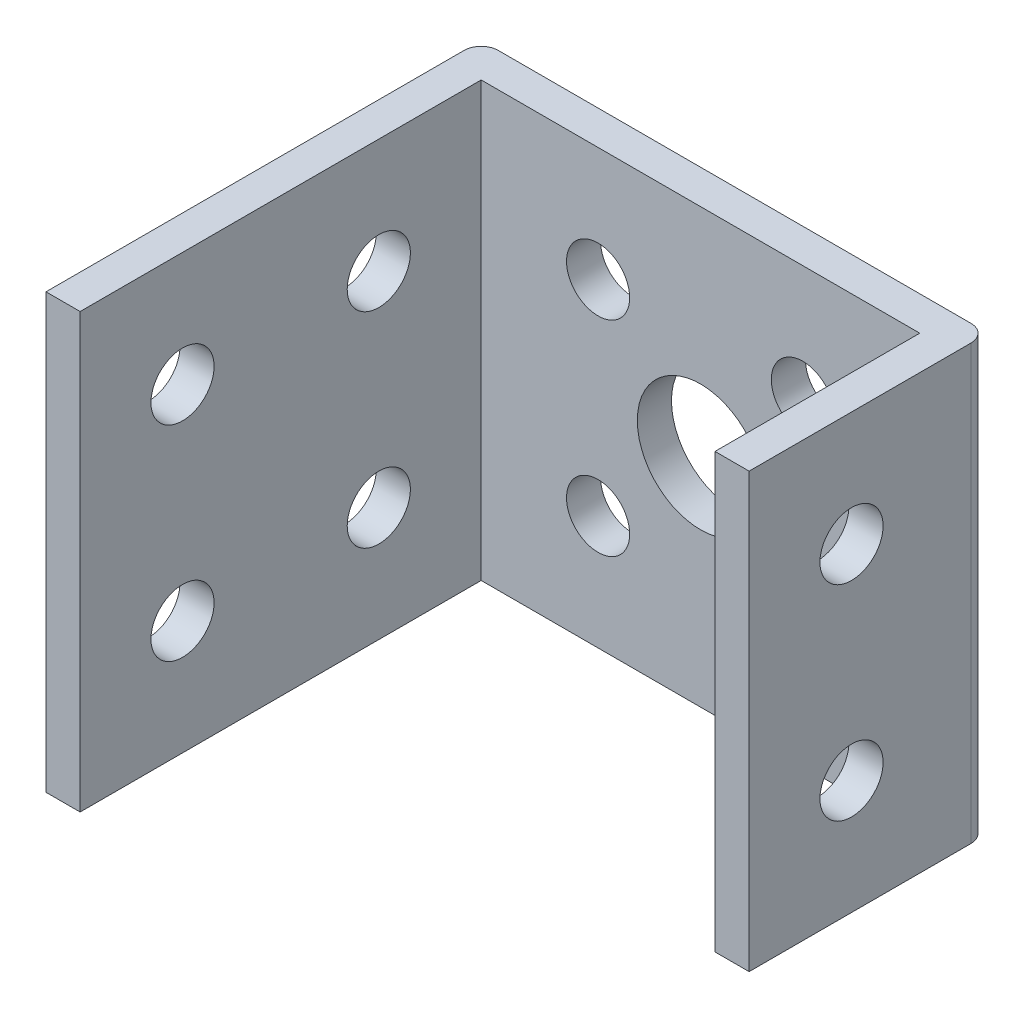
from build123d import *

# Parameters (mm, degrees)
BOSS_EXTRUDE1_DEPTH = 12.7
SKETCH2_R           = 1.85
CUT_EXTRUDE1_DEPTH  = 30.7
SKETCH3_R           = 3.7
CUT_EXTRUDE2_DEPTH  = 15
SKETCH4_R           = 1.85
CUT_EXTRUDE3_DEPTH  = 3
SKETCH5_W           = 11.5
SKETCH5_H           = 25.4
SKETCH5_R           = 1.85
BOSS_EXTRUDE2_DEPTH = 2
FILLET1_R           = 1


with BuildPart() as part:
    # Sketch1 → Boss-Extrude1 (new body, symmetric)
    with BuildSketch(Plane(origin=(0, 0, 0), x_dir=(1, 0, 0), z_dir=(0, 1, 0))):
        Polygon((-14.85, 0), (14.85, 0), (14.85, -14), (12.85, -14), (12.85, -2), (-12.85, -2), (-12.85, -14), (-14.85, -14), align=None)
    extrude(amount=BOSS_EXTRUDE1_DEPTH, both=True)

    # Sketch2 → Cut-Extrude1 (cut, through all)
    with BuildSketch(Plane.ZY.offset(14.85)):
        with Locations((8, -6)):
            Circle(SKETCH2_R)
        with Locations((8, 6)):
            Circle(SKETCH2_R)
    extrude(amount=-CUT_EXTRUDE1_DEPTH, mode=Mode.SUBTRACT)

    # Sketch3 → Cut-Extrude2 (cut, through all)
    with BuildSketch(Plane(origin=(0, 0, 0), x_dir=(-1, 0, 0), z_dir=(0, 0, -1))):
        Circle(SKETCH3_R)
    extrude(amount=-CUT_EXTRUDE2_DEPTH, mode=Mode.SUBTRACT)

    # Sketch4 → Cut-Extrude3 (cut, through all)
    with BuildSketch(Plane.XY.offset(2)):
        with Locations((-6, 6)):
            Circle(SKETCH4_R)
        with Locations((-6, -6)):
            Circle(SKETCH4_R)
        with Locations((6, -6)):
            Circle(SKETCH4_R)
        with Locations((6, 6)):
            Circle(SKETCH4_R)
    extrude(amount=-CUT_EXTRUDE3_DEPTH, mode=Mode.SUBTRACT)

    # Sketch5 → Boss-Extrude2 (add)
    with BuildSketch(Plane(origin=(-14.85, 0, 0), x_dir=(0, 0, -1), z_dir=(1, 0, 0))):
        with Locations((-19.75, 0)):
            Rectangle(SKETCH5_W, SKETCH5_H)
        with Locations((-19.5, 6)):
            Circle(SKETCH5_R, mode=Mode.SUBTRACT)
        with Locations((-19.5, -6)):
            Circle(SKETCH5_R, mode=Mode.SUBTRACT)
    extrude(amount=BOSS_EXTRUDE2_DEPTH)

    # Fillet1
    fillet1_edges = [part.edges().sort_by_distance(p)[0] for p in [
        (-14.85, 0, 0),
        (14.85, 0, 0),
    ]]
    fillet(fillet1_edges, radius=FILLET1_R)


solid = part.part
